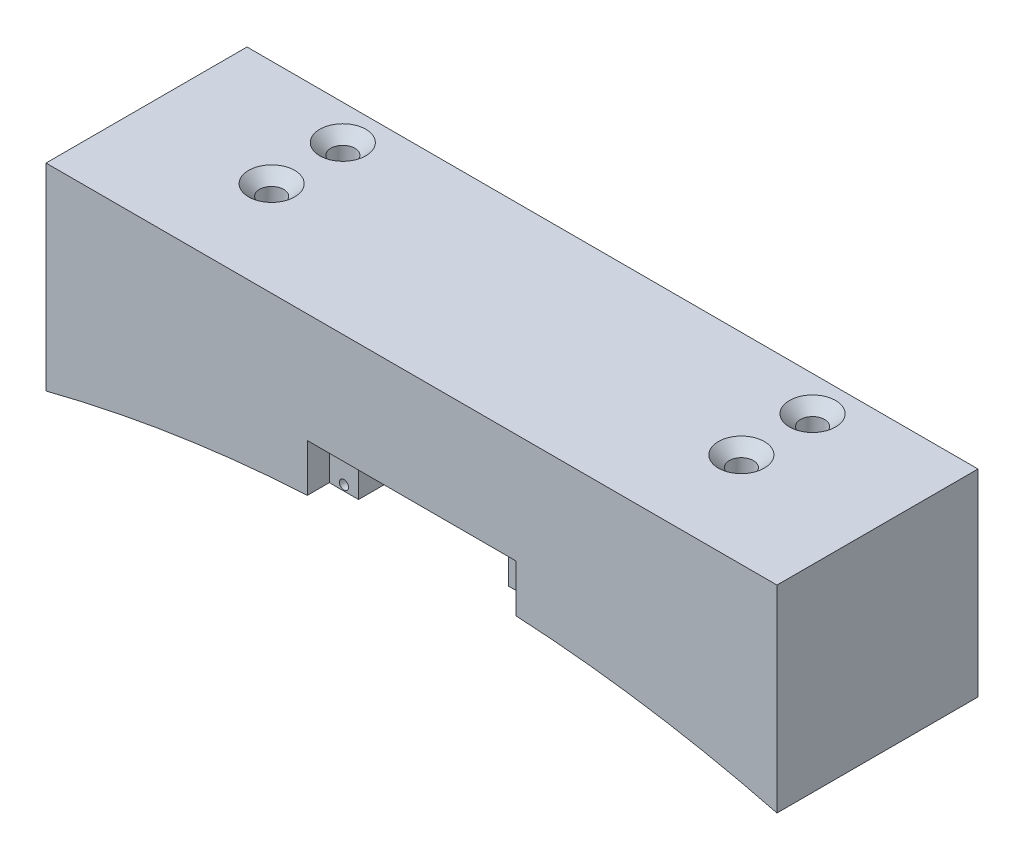
from build123d import *

# Parameters (mm, degrees)
SKETCH1_W                                       = 200
SKETCH1_H                                       = 55
BOSS_EXTRUDE1_DEPTH                             = 30
SKETCH2_W                                       = 8
SKETCH2_H                                       = 20
BOSS_EXTRUDE2_DEPTH                             = 13
SKETCH7_R                                       = 1.25
CUT_EXTRUDE1_DEPTH                              = 49.984212522
SKETCH11_R                                      = 1.25
CUT_EXTRUDE2_DEPTH                              = 13
SKETCH13_W                                      = 71.503175403
SKETCH13_H                                      = 55
SKETCH13_W_2                                    = 71.456081763
BOSS_EXTRUDE3_DEPTH                             = 13
BOSS_EXTRUDE4_DEPTH                             = 55
CSK_FOR_M6_FLAT_HEAD_MACHINE_SCREW2_D           = 6.6
CSK_FOR_M6_FLAT_HEAD_MACHINE_SCREW2_CSINK_D     = 12.6
CSK_FOR_M6_FLAT_HEAD_MACHINE_SCREW2_CSINK_ANGLE = 90


with BuildPart() as part:
    # Sketch1 → Boss-Extrude1 (new body)
    with BuildSketch(Plane(origin=(0, 0, 0), x_dir=(1, 0, 0), z_dir=(0, 1, 0))):
        Rectangle(SKETCH1_W, SKETCH1_H)
    extrude(amount=BOSS_EXTRUDE1_DEPTH)

    # Sketch2 → Boss-Extrude2 (add)
    with BuildSketch(Plane.XZ):
        with Locations((-24.5, 11.484212522)):
            Rectangle(SKETCH2_W, SKETCH2_H)
        with Locations((24.5, 11.484212522)):
            Rectangle(SKETCH2_W, SKETCH2_H)
    extrude(amount=BOSS_EXTRUDE2_DEPTH)

    # Sketch7 → Cut-Extrude1 (cut, through all)
    with BuildSketch(Plane.XY.offset(21.484212522)):
        with Locations((-24.5, -1.5)):
            Circle(SKETCH7_R)
        with Locations((-24.5, -11.5)):
            Circle(SKETCH7_R)
    extrude(amount=-CUT_EXTRUDE1_DEPTH, mode=Mode.SUBTRACT)

    # Sketch11 → Cut-Extrude2 (cut)
    with BuildSketch(Plane.XY.offset(21.484212522)):
        with Locations((24.5, -1.5)):
            Circle(SKETCH11_R)
        with Locations((24.5, -11.5)):
            Circle(SKETCH11_R)
    extrude(amount=-CUT_EXTRUDE2_DEPTH, mode=Mode.SUBTRACT)

    # Sketch13 → Boss-Extrude3 (add)
    with BuildSketch(Plane.XZ):
        with Locations((-64.248412298, 0)):
            Rectangle(SKETCH13_W, SKETCH13_H)
        with Locations((64.271959119, 0)):
            Rectangle(SKETCH13_W_2, SKETCH13_H)
    extrude(amount=BOSS_EXTRUDE3_DEPTH)

    # Sketch26 → Boss-Extrude4 (add, through all)
    with BuildSketch(Plane.XY.offset(27.5)):
        with BuildLine():
            Line((100, -24.02177079), (100, -13))
            Line((100, -13), (28.543918237, -13))
            ThreePointArc((28.543918237, -13), (64.542951108, -16.753996588), (100, -24.02177079))
        make_face()
        with BuildLine():
            Line((-100, -24.02177079), (-100, -13))
            Line((-100, -13), (-28.543918237, -13))
            ThreePointArc((-28.543918237, -13), (-64.542951108, -16.753996588), (-100, -24.02177079))
        make_face()
    extrude(amount=-BOSS_EXTRUDE4_DEPTH)

    # CSK for M6 Flat Head Machine Screw2 (through all)
    with Locations(Plane(origin=(-64.248412299, 30, -17.95872272), x_dir=(0, 0, 1), z_dir=(0, 1, 0))):
        with Locations((0, 0), (0, 128.520371417), (19.47835626, 0), (19.47835626, 128.520371417)):
            CounterSinkHole(CSK_FOR_M6_FLAT_HEAD_MACHINE_SCREW2_D / 2, CSK_FOR_M6_FLAT_HEAD_MACHINE_SCREW2_CSINK_D / 2, counter_sink_angle=CSK_FOR_M6_FLAT_HEAD_MACHINE_SCREW2_CSINK_ANGLE)


solid = part.part
